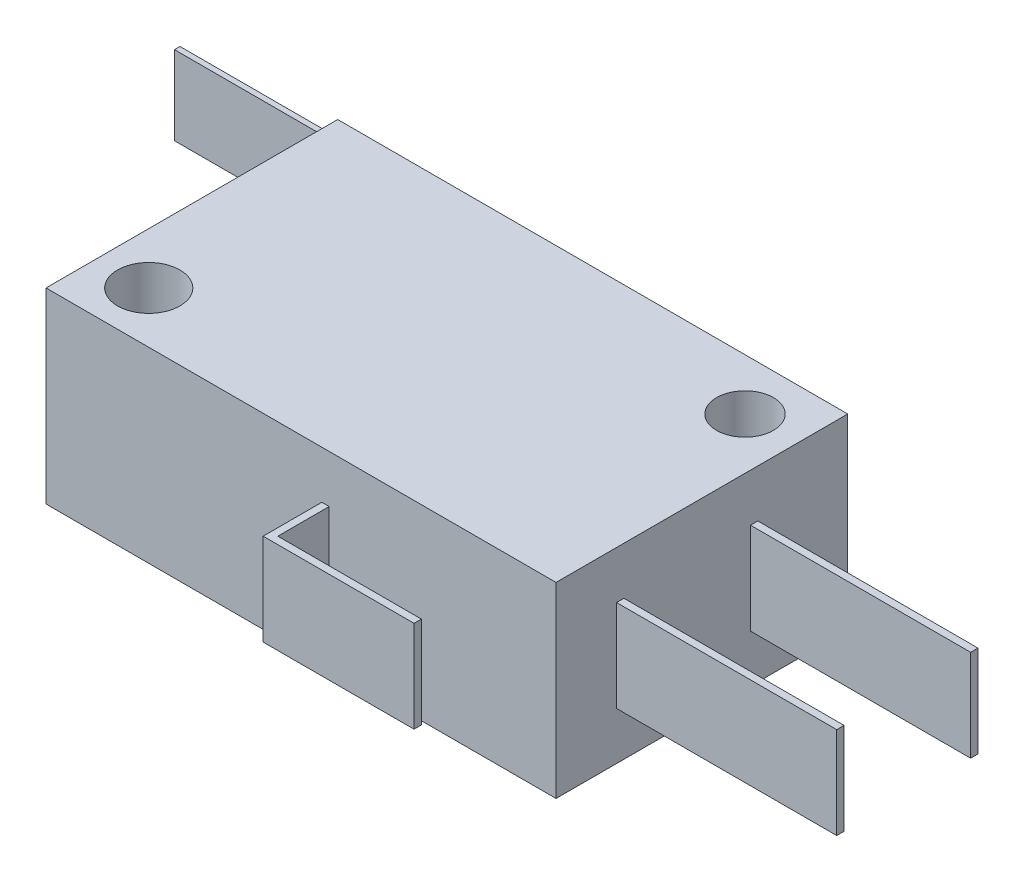
from build123d import *

# Parameters (mm, degrees)
SKETCH1_W               = 27.8
SKETCH1_H               = 15.9
BOSS_EXTRUDE1_DEPTH     = 5.1
SKETCH2_R               = 1.55
SKETCH2_R_2             = 1.7
CUT_EXTRUDE1_DEPTH      = 6.1
CUT_EXTRUDE1_DEPTH_BACK = 6.1
BOSS_EXTRUDE2_DEPTH     = 2.15
SKETCH4_R               = 1.8
BOSS_EXTRUDE6_DEPTH     = 2.15
SKETCH5_W               = 12
SKETCH5_H               = 0.4
BOSS_EXTRUDE7_DEPTH     = 2.5
LPATTERN1_COUNT         = 2
LPATTERN1_PITCH         = 7.3
BOSS_EXTRUDE8_DEPTH     = 2.5


with BuildPart() as part:
    # Sketch1 → Boss-Extrude1 (new body, symmetric)
    with BuildSketch(Plane(origin=(0, 0, 0), x_dir=(1, 0, 0), z_dir=(0, 1, 0))):
        Rectangle(SKETCH1_W, SKETCH1_H)
    extrude(amount=BOSS_EXTRUDE1_DEPTH, both=True)

    # Sketch2 → Cut-Extrude1 (cut, two sides)
    with BuildSketch(Plane(origin=(0, 0, 0), x_dir=(1, 0, 0), z_dir=(0, 1, 0))) as cut_extrude1_sk:
        with Locations((11.1, 5.15)):
            Circle(SKETCH2_R)
        with Locations((-11.1, -5.15)):
            Circle(SKETCH2_R_2)
    extrude(amount=CUT_EXTRUDE1_DEPTH, mode=Mode.SUBTRACT)
    extrude(cut_extrude1_sk.sketch, amount=-CUT_EXTRUDE1_DEPTH_BACK, mode=Mode.SUBTRACT)

    # Sketch3 → Boss-Extrude2 (add, symmetric)
    with BuildSketch(Plane(origin=(0, 0, 0), x_dir=(1, 0, 0), z_dir=(0, 1, 0))):
        Polygon((2.9, 7.95), (2.9, 10.05), (-24.6, 10.05), (-24.6, 9.75), (2.6, 9.75), (2.6, 7.95), align=None)
    extrude(amount=BOSS_EXTRUDE2_DEPTH, both=True)

    # Sketch5 → Boss-Extrude7 (add, symmetric)
    with BuildSketch(Plane(origin=(0, 0, 0), x_dir=(1, 0, 0), z_dir=(0, 1, 0))):
        with Locations((19.9, 2.85)):
            Rectangle(SKETCH5_W, SKETCH5_H)
    boss_extrude7 = extrude(amount=BOSS_EXTRUDE7_DEPTH, both=True)

    # LPattern1: Boss-Extrude7 ×2
    with Locations(*[(0, 0, i * LPATTERN1_PITCH) for i in range(1, LPATTERN1_COUNT)]):
        add(boss_extrude7)

    # Sketch6 → Boss-Extrude8 (add, symmetric)
    with BuildSketch(Plane(origin=(0, 0, 0), x_dir=(1, 0, 0), z_dir=(0, 1, 0))):
        Polygon((1.535522272, -7.95), (1.535522272, -10.75), (9.361043521, -10.75), (9.361043521, -11.15), (1.135522272, -11.15), (1.135522272, -7.95), align=None)
    extrude(amount=BOSS_EXTRUDE8_DEPTH, both=True)


with BuildPart() as body_2:
    # Sketch4 → Boss-Extrude6 (new body, symmetric)
    with BuildSketch(Plane(origin=(0, 0, 0), x_dir=(1, 0, 0), z_dir=(0, 1, 0))):
        with Locations((-8.899200678, 7.95)):
            Circle(SKETCH4_R)
    extrude(amount=BOSS_EXTRUDE6_DEPTH, both=True)


solid = Compound([part.part, body_2.part])
